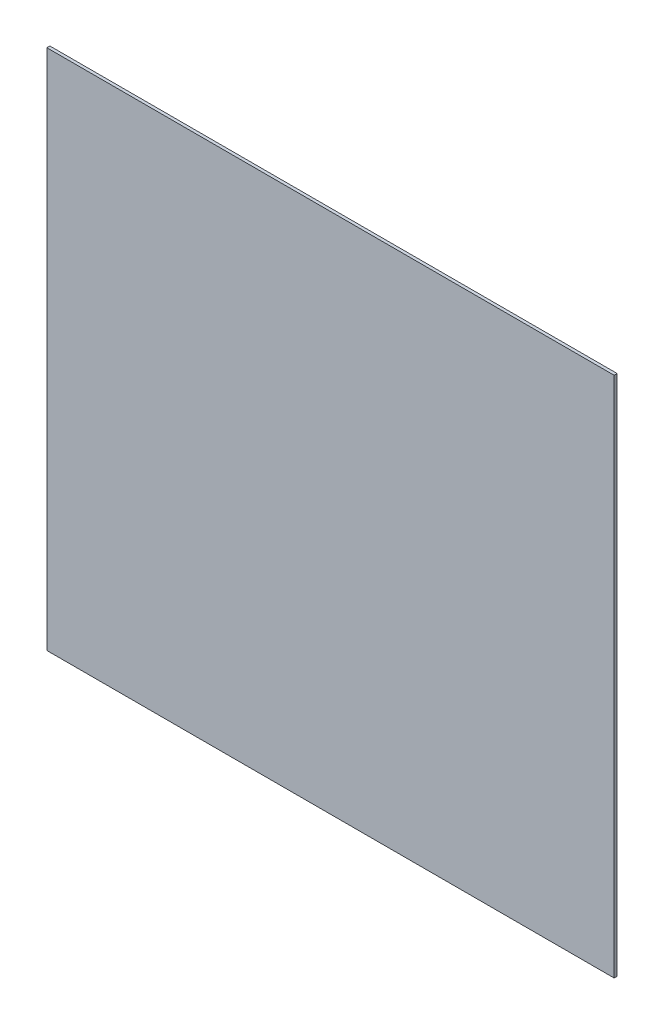
from build123d import *

# Parameters (mm, degrees)
SKICA1_W                = 565
SKICA1_H                = 520
P_IDAT_VYSUNUT_M1_DEPTH = 3


with BuildPart() as part:
    # Skica1 → Přidat vysunutím1 (new body)
    with BuildSketch(Plane.XY):
        Rectangle(SKICA1_W, SKICA1_H)
    extrude(amount=P_IDAT_VYSUNUT_M1_DEPTH)


solid = part.part
